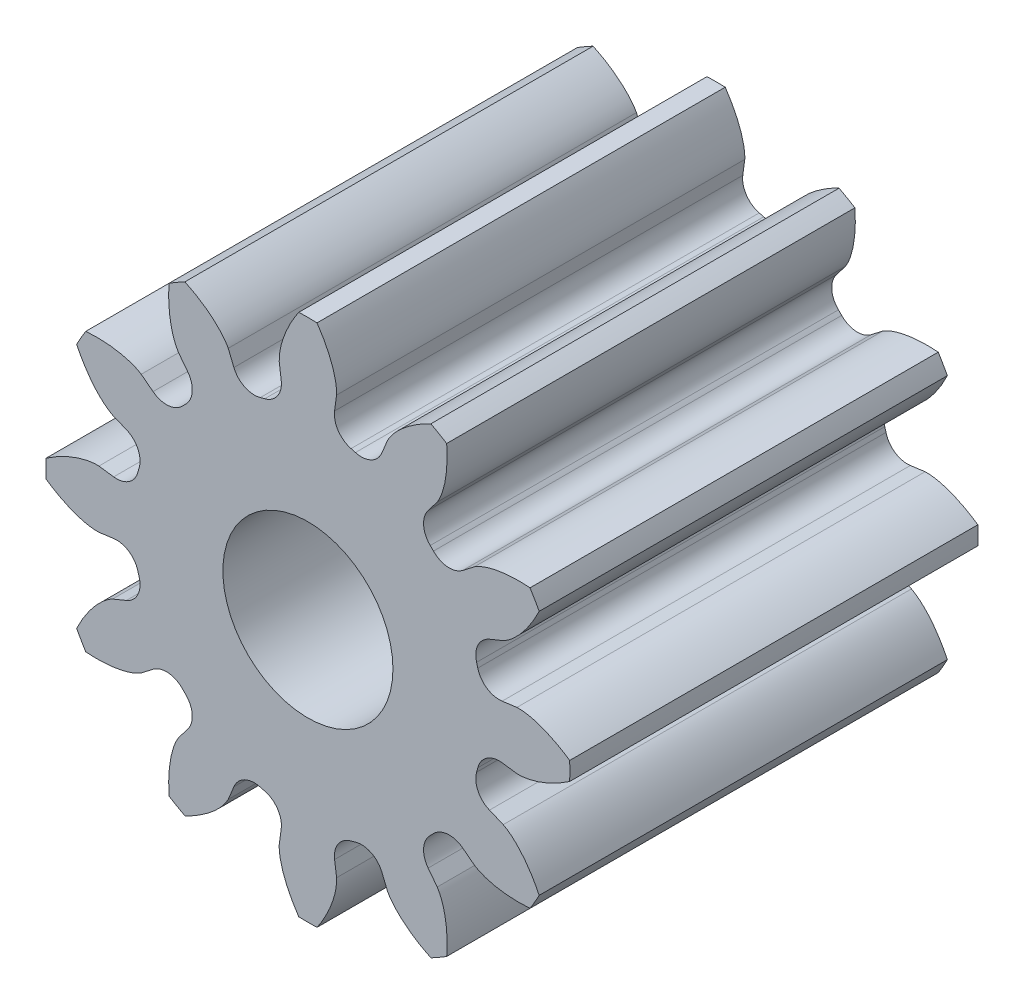
from build123d import *

# Parameters (mm, degrees)
SKETCH1_R           = 1
BOSS_EXTRUDE1_DEPTH = 4.8


with BuildPart() as part:
    # Sketch1 → Boss-Extrude1 (new body)
    with BuildSketch(Plane(origin=(0, 0, 0), x_dir=(-1, 0, 0), z_dir=(0, 0, -1))):
        with BuildLine():
            Line((-1.41382185, -1.821043659), (-1.520882243, -1.959905324))
            add(Edge.make_bspline(
                [(-1.520882243, -1.959905324), (-1.665571723, -2.186935576), (-1.632082373, -2.612031227)],
                knots=[0.532425482, 0.532425482, 0.532425482, 1.592668284, 1.592668284, 1.592668284], degree=2, weights=[1, 0.862745692, 1]))
            ThreePointArc((-1.632082373, -2.612031227), (-1.54, -2.667358244), (-1.446044211, -2.719440409))
            add(Edge.make_bspline(
                [(-1.446044211, -2.719440409), (-1.061155904, -2.535895212), (-0.936886678, -2.297075321)],
                knots=[1.548924369, 1.548924369, 1.548924369, 2.609167171, 2.609167171, 2.609167171], degree=2, weights=[1, 0.862745692, 1]))
            Line((-0.936886678, -2.297075321), (-0.870159145, -2.134927467))
            ThreePointArc((-0.870159145, -2.134927467), (-0.743603071, -2.000223961), (-0.559505179, -1.983809314))
            ThreePointArc((-0.559505179, -1.983809314), (-0.533477816, -1.990966313), (-0.507358959, -1.997781852))
            ThreePointArc((-0.507358959, -1.997781852), (-0.356132831, -2.104046299), (-0.313883809, -2.283980995))
            Line((-0.313883809, -2.283980995), (-0.337169997, -2.457768921))
            add(Edge.make_bspline(
                [(-0.337169997, -2.457768921), (-0.348959636, -2.726727627), (-0.107409182, -3.078126584)],
                knots=[3.674018136, 3.674018136, 3.674018136, 4.734260938, 4.734260938, 4.734260938], degree=2, weights=[1, 0.862745692, 1]))
            ThreePointArc((-0.107409182, -3.078126584), (0, -3.08), (0.107409182, -3.078126584))
            add(Edge.make_bspline(
                [(0.107409182, -3.078126584), (0.348959636, -2.726727627), (0.337169997, -2.457768921)],
                knots=[1.548924369, 1.548924369, 1.548924369, 2.609167171, 2.609167171, 2.609167171], degree=2, weights=[1, 0.862745692, 1]))
            Line((0.337169997, -2.457768921), (0.313883809, -2.283980995))
            ThreePointArc((0.313883809, -2.283980995), (0.356132831, -2.104046299), (0.507358959, -1.997781852))
            ThreePointArc((0.507358959, -1.997781852), (0.533477816, -1.990966313), (0.559505179, -1.983809314))
            ThreePointArc((0.559505179, -1.983809314), (0.743603071, -2.000223961), (0.870159145, -2.134927467))
            Line((0.870159145, -2.134927467), (0.936886678, -2.297075321))
            add(Edge.make_bspline(
                [(0.936886678, -2.297075321), (1.061155904, -2.535895212), (1.446044211, -2.719440409)],
                knots=[0.532425482, 0.532425482, 0.532425482, 1.592668284, 1.592668284, 1.592668284], degree=2, weights=[1, 0.862745692, 1]))
            ThreePointArc((1.446044211, -2.719440409), (1.54, -2.667358244), (1.632082373, -2.612031227))
            add(Edge.make_bspline(
                [(1.632082373, -2.612031227), (1.665571723, -2.186935576), (1.520882243, -1.959905324)],
                knots=[1.548924369, 1.548924369, 1.548924369, 2.609167171, 2.609167171, 2.609167171], degree=2, weights=[1, 0.862745692, 1]))
            Line((1.520882243, -1.959905324), (1.41382185, -1.821043659))
            ThreePointArc((1.41382185, -1.821043659), (1.360443228, -1.64409113), (1.438276673, -1.476450355))
            ThreePointArc((1.438276673, -1.476450355), (1.457488497, -1.457488497), (1.476450355, -1.438276673))
            ThreePointArc((1.476450355, -1.438276673), (1.64409113, -1.360443228), (1.821043659, -1.41382185))
            Line((1.821043659, -1.41382185), (1.959905324, -1.520882243))
            add(Edge.make_bspline(
                [(1.959905324, -1.520882243), (2.186935576, -1.665571723), (2.612031227, -1.632082373)],
                knots=[0.532425482, 0.532425482, 0.532425482, 1.592668284, 1.592668284, 1.592668284], degree=2, weights=[1, 0.862745692, 1]))
            ThreePointArc((2.612031227, -1.632082373), (2.667358244, -1.54), (2.719440409, -1.446044211))
            add(Edge.make_bspline(
                [(2.719440409, -1.446044211), (2.535895212, -1.061155904), (2.297075321, -0.936886678)],
                knots=[1.548924369, 1.548924369, 1.548924369, 2.609167171, 2.609167171, 2.609167171], degree=2, weights=[1, 0.862745692, 1]))
            Line((2.297075321, -0.936886678), (2.134927467, -0.870159145))
            ThreePointArc((2.134927467, -0.870159145), (2.000223961, -0.743603071), (1.983809314, -0.559505179))
            ThreePointArc((1.983809314, -0.559505179), (1.990966313, -0.533477816), (1.997781852, -0.507358959))
            ThreePointArc((1.997781852, -0.507358959), (2.104046299, -0.356132831), (2.283980995, -0.313883809))
            Line((2.283980995, -0.313883809), (2.457768921, -0.337169997))
            add(Edge.make_bspline(
                [(2.457768921, -0.337169997), (2.726727627, -0.348959636), (3.078126584, -0.107409182)],
                knots=[0.532425482, 0.532425482, 0.532425482, 1.592668284, 1.592668284, 1.592668284], degree=2, weights=[1, 0.862745692, 1]))
            ThreePointArc((3.078126584, -0.107409182), (3.08, 0), (3.078126584, 0.107409182))
            add(Edge.make_bspline(
                [(3.078126584, 0.107409182), (2.726727627, 0.348959636), (2.457768921, 0.337169997)],
                knots=[4.690517023, 4.690517023, 4.690517023, 5.750759825, 5.750759825, 5.750759825], degree=2, weights=[1, 0.862745692, 1]))
            Line((2.457768921, 0.337169997), (2.283980995, 0.313883809))
            ThreePointArc((2.283980995, 0.313883809), (2.104046299, 0.356132831), (1.997781852, 0.507358959))
            ThreePointArc((1.997781852, 0.507358959), (1.990966313, 0.533477816), (1.983809314, 0.559505179))
            ThreePointArc((1.983809314, 0.559505179), (2.000223961, 0.743603071), (2.134927467, 0.870159145))
            Line((2.134927467, 0.870159145), (2.297075321, 0.936886678))
            add(Edge.make_bspline(
                [(2.297075321, 0.936886678), (2.535895212, 1.061155904), (2.719440409, 1.446044211)],
                knots=[3.674018136, 3.674018136, 3.674018136, 4.734260938, 4.734260938, 4.734260938], degree=2, weights=[1, 0.862745692, 1]))
            ThreePointArc((2.719440409, 1.446044211), (2.667358244, 1.54), (2.612031227, 1.632082373))
            add(Edge.make_bspline(
                [(2.612031227, 1.632082373), (2.186935576, 1.665571723), (1.959905324, 1.520882243)],
                knots=[4.690517023, 4.690517023, 4.690517023, 5.750759825, 5.750759825, 5.750759825], degree=2, weights=[1, 0.862745692, 1]))
            Line((1.959905324, 1.520882243), (1.821043659, 1.41382185))
            ThreePointArc((1.821043659, 1.41382185), (1.64409113, 1.360443228), (1.476450355, 1.438276673))
            ThreePointArc((1.476450355, 1.438276673), (1.457488497, 1.457488497), (1.438276673, 1.476450355))
            ThreePointArc((1.438276673, 1.476450355), (1.360443228, 1.64409113), (1.41382185, 1.821043659))
            Line((1.41382185, 1.821043659), (1.520882243, 1.959905324))
            add(Edge.make_bspline(
                [(1.520882243, 1.959905324), (1.665571723, 2.186935576), (1.632082373, 2.612031227)],
                knots=[3.674018136, 3.674018136, 3.674018136, 4.734260938, 4.734260938, 4.734260938], degree=2, weights=[1, 0.862745692, 1]))
            ThreePointArc((1.632082373, 2.612031227), (1.54, 2.667358244), (1.446044211, 2.719440409))
            add(Edge.make_bspline(
                [(1.446044211, 2.719440409), (1.061155904, 2.535895212), (0.936886678, 2.297075321)],
                knots=[4.690517023, 4.690517023, 4.690517023, 5.750759825, 5.750759825, 5.750759825], degree=2, weights=[1, 0.862745692, 1]))
            Line((0.936886678, 2.297075321), (0.870159145, 2.134927467))
            ThreePointArc((0.870159145, 2.134927467), (0.743603071, 2.000223961), (0.559505179, 1.983809314))
            ThreePointArc((0.559505179, 1.983809314), (0.533477816, 1.990966313), (0.507358959, 1.997781852))
            ThreePointArc((0.507358959, 1.997781852), (0.356132831, 2.104046299), (0.313883809, 2.283980995))
            Line((0.313883809, 2.283980995), (0.337169997, 2.457768921))
            add(Edge.make_bspline(
                [(0.337169997, 2.457768921), (0.348959636, 2.726727627), (0.107409182, 3.078126584)],
                knots=[3.674018136, 3.674018136, 3.674018136, 4.734260938, 4.734260938, 4.734260938], degree=2, weights=[1, 0.862745692, 1]))
            ThreePointArc((0.107409182, 3.078126584), (0, 3.08), (-0.107409182, 3.078126584))
            add(Edge.make_bspline(
                [(-0.107409182, 3.078126584), (-0.348959636, 2.726727627), (-0.337169997, 2.457768921)],
                knots=[4.690517023, 4.690517023, 4.690517023, 5.750759825, 5.750759825, 5.750759825], degree=2, weights=[1, 0.862745692, 1]))
            Line((-0.337169997, 2.457768921), (-0.313883809, 2.283980995))
            ThreePointArc((-0.313883809, 2.283980995), (-0.356132831, 2.104046299), (-0.507358959, 1.997781852))
            ThreePointArc((-0.507358959, 1.997781852), (-0.533477816, 1.990966313), (-0.559505179, 1.983809314))
            ThreePointArc((-0.559505179, 1.983809314), (-0.743603071, 2.000223961), (-0.870159145, 2.134927467))
            Line((-0.870159145, 2.134927467), (-0.936886678, 2.297075321))
            add(Edge.make_bspline(
                [(-0.936886678, 2.297075321), (-1.061155904, 2.535895212), (-1.446044211, 2.719440409)],
                knots=[3.674018136, 3.674018136, 3.674018136, 4.734260938, 4.734260938, 4.734260938], degree=2, weights=[1, 0.862745692, 1]))
            ThreePointArc((-1.446044211, 2.719440409), (-1.54, 2.667358244), (-1.632082373, 2.612031227))
            add(Edge.make_bspline(
                [(-1.632082373, 2.612031227), (-1.665571723, 2.186935576), (-1.520882243, 1.959905324)],
                knots=[1.548924369, 1.548924369, 1.548924369, 2.609167171, 2.609167171, 2.609167171], degree=2, weights=[1, 0.862745692, 1]))
            Line((-1.520882243, 1.959905324), (-1.41382185, 1.821043659))
            ThreePointArc((-1.41382185, 1.821043659), (-1.360443228, 1.64409113), (-1.438276673, 1.476450355))
            ThreePointArc((-1.438276673, 1.476450355), (-1.457488497, 1.457488497), (-1.476450355, 1.438276673))
            ThreePointArc((-1.476450355, 1.438276673), (-1.64409113, 1.360443228), (-1.821043659, 1.41382185))
            Line((-1.821043659, 1.41382185), (-1.959905324, 1.520882243))
            add(Edge.make_bspline(
                [(-1.959905324, 1.520882243), (-2.186935576, 1.665571723), (-2.612031227, 1.632082373)],
                knots=[3.674018136, 3.674018136, 3.674018136, 4.734260938, 4.734260938, 4.734260938], degree=2, weights=[1, 0.862745692, 1]))
            ThreePointArc((-2.612031227, 1.632082373), (-2.667358244, 1.54), (-2.719440409, 1.446044211))
            add(Edge.make_bspline(
                [(-2.719440409, 1.446044211), (-2.535895212, 1.061155904), (-2.297075321, 0.936886678)],
                knots=[1.548924369, 1.548924369, 1.548924369, 2.609167171, 2.609167171, 2.609167171], degree=2, weights=[1, 0.862745692, 1]))
            Line((-2.297075321, 0.936886678), (-2.134927467, 0.870159145))
            ThreePointArc((-2.134927467, 0.870159145), (-2.000223961, 0.743603071), (-1.983809314, 0.559505179))
            ThreePointArc((-1.983809314, 0.559505179), (-1.990966313, 0.533477816), (-1.997781852, 0.507358959))
            ThreePointArc((-1.997781852, 0.507358959), (-2.104046299, 0.356132831), (-2.283980995, 0.313883809))
            Line((-2.283980995, 0.313883809), (-2.457768921, 0.337169997))
            add(Edge.make_bspline(
                [(-2.457768921, 0.337169997), (-2.726727627, 0.348959636), (-3.078126584, 0.107409182)],
                knots=[3.674018136, 3.674018136, 3.674018136, 4.734260938, 4.734260938, 4.734260938], degree=2, weights=[1, 0.862745692, 1]))
            ThreePointArc((-3.078126584, 0.107409182), (-3.08, 0), (-3.078126584, -0.107409182))
            add(Edge.make_bspline(
                [(-3.078126584, -0.107409182), (-2.726727627, -0.348959636), (-2.457768921, -0.337169997)],
                knots=[1.548924369, 1.548924369, 1.548924369, 2.609167171, 2.609167171, 2.609167171], degree=2, weights=[1, 0.862745692, 1]))
            Line((-2.457768921, -0.337169997), (-2.283980995, -0.313883809))
            ThreePointArc((-2.283980995, -0.313883809), (-2.104046299, -0.356132831), (-1.997781852, -0.507358959))
            ThreePointArc((-1.997781852, -0.507358959), (-1.990966313, -0.533477816), (-1.983809314, -0.559505179))
            ThreePointArc((-1.983809314, -0.559505179), (-2.000223961, -0.743603071), (-2.134927467, -0.870159145))
            Line((-2.134927467, -0.870159145), (-2.297075321, -0.936886678))
            add(Edge.make_bspline(
                [(-2.297075321, -0.936886678), (-2.535895212, -1.061155904), (-2.719440409, -1.446044211)],
                knots=[0.532425482, 0.532425482, 0.532425482, 1.592668284, 1.592668284, 1.592668284], degree=2, weights=[1, 0.862745692, 1]))
            ThreePointArc((-2.719440409, -1.446044211), (-2.667358244, -1.54), (-2.612031227, -1.632082373))
            add(Edge.make_bspline(
                [(-2.612031227, -1.632082373), (-2.186935576, -1.665571723), (-1.959905324, -1.520882243)],
                knots=[1.548924369, 1.548924369, 1.548924369, 2.609167171, 2.609167171, 2.609167171], degree=2, weights=[1, 0.862745692, 1]))
            Line((-1.959905324, -1.520882243), (-1.821043659, -1.41382185))
            ThreePointArc((-1.821043659, -1.41382185), (-1.64409113, -1.360443228), (-1.476450355, -1.438276673))
            ThreePointArc((-1.476450355, -1.438276673), (-1.457488497, -1.457488497), (-1.438276673, -1.476450355))
            ThreePointArc((-1.438276673, -1.476450355), (-1.360443228, -1.64409113), (-1.41382185, -1.821043659))
        make_face()
        Circle(SKETCH1_R, mode=Mode.SUBTRACT)
    extrude(amount=-BOSS_EXTRUDE1_DEPTH)


solid = part.part
